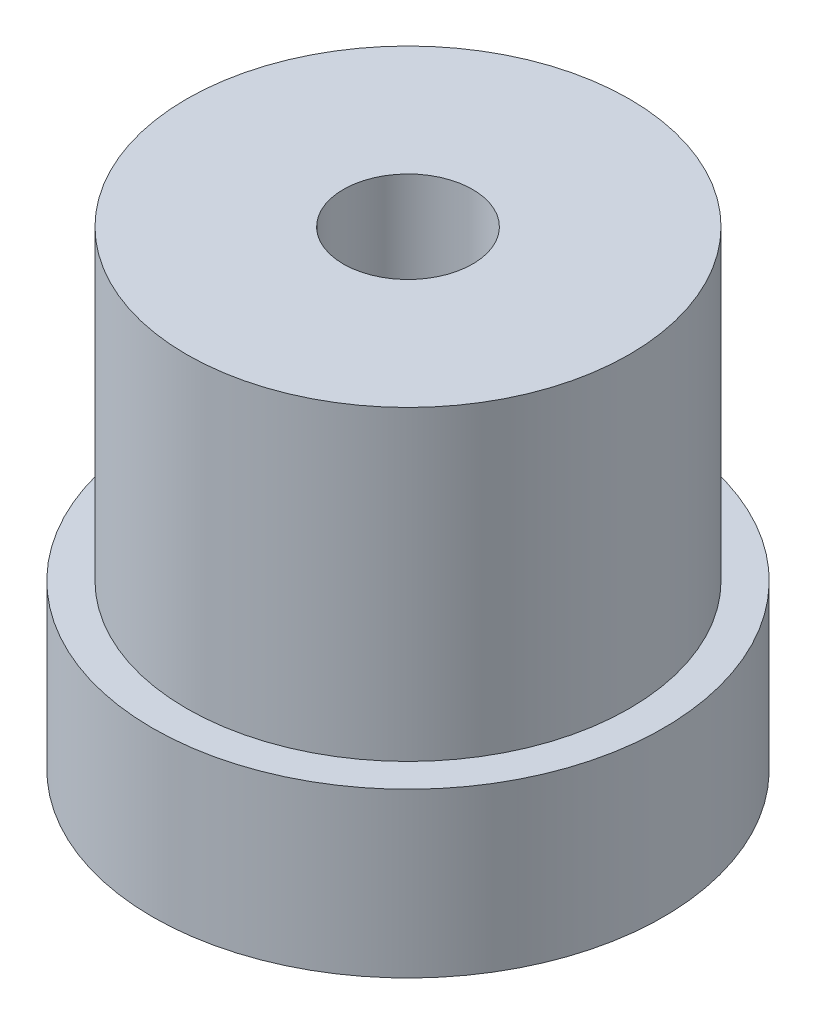
from build123d import *

# Parameters (mm, degrees)
M3X0_5_TAPPED_HOLE1_D      = 2.5
M3X0_5_TAPPED_HOLE1_DEPTH  = 7.5
M3X0_5_TAPPED_HOLE1_TIP    = 0.751075774
F_10_24_TAPPED_HOLE1_D     = 3.7973
F_10_24_TAPPED_HOLE1_DEPTH = 10
F_10_24_TAPPED_HOLE1_TIP   = 1.140824014


with BuildPart() as part:
    # Sketch1 → Revolve1 (revolve)
    with BuildSketch(Plane.XY):
        Polygon((0, 13.8025), (6.5, 13.8025), (6.5, 4.8), (7.5, 4.8), (7.5, 0), (0, 0), align=None)
    revolve(axis=Axis((0, 0, 0), (0, 1, 0)))

    # M3x0.5 Tapped Hole1
    with Locations(Plane(origin=(0, 0, 0), x_dir=(-1, 0, 0), z_dir=(0, -1, 0))):
        with Locations((0, 5), (4.330127019, -2.5), (-4.330127019, -2.5)):
            Hole(M3X0_5_TAPPED_HOLE1_D / 2, depth=M3X0_5_TAPPED_HOLE1_DEPTH)
            with Locations((0, 0, -(M3X0_5_TAPPED_HOLE1_DEPTH + M3X0_5_TAPPED_HOLE1_TIP / 2))):  # 118° drill point
                Cone(0, M3X0_5_TAPPED_HOLE1_D / 2, M3X0_5_TAPPED_HOLE1_TIP, mode=Mode.SUBTRACT)

    # #10-24 Tapped Hole1
    with Locations(Plane(origin=(0, 13.8025, 0), x_dir=(1, 0, 0), z_dir=(0, 1, 0))):
        with Locations((0, 0)):
            Hole(F_10_24_TAPPED_HOLE1_D / 2, depth=F_10_24_TAPPED_HOLE1_DEPTH)
            with Locations((0, 0, -(F_10_24_TAPPED_HOLE1_DEPTH + F_10_24_TAPPED_HOLE1_TIP / 2))):  # 118° drill point
                Cone(0, F_10_24_TAPPED_HOLE1_D / 2, F_10_24_TAPPED_HOLE1_TIP, mode=Mode.SUBTRACT)


solid = part.part
